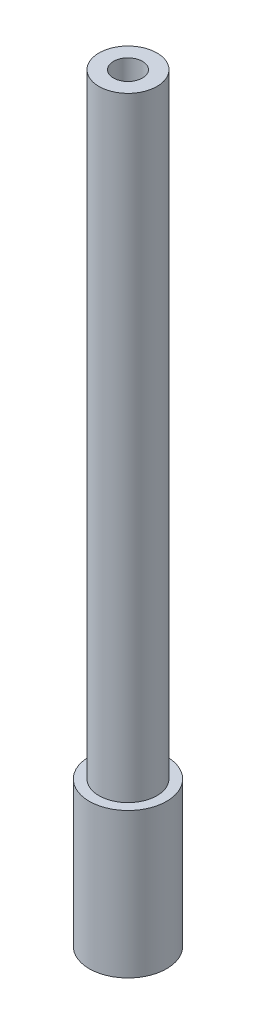
from build123d import *

# Parameters (mm, degrees)
SKETCH1_R           = 4
BOSS_EXTRUDE1_DEPTH = 15
SKETCH2_R           = 3
BOSS_EXTRUDE2_DEPTH = 59.52
SKETCH3_R           = 2.425
SKETCH3_R_2         = 1.02
CUT_EXTRUDE1_DEPTH  = 4
SKETCH4_R           = 3
BOSS_EXTRUDE3_DEPTH = 4
SKETCH5_R           = 1.5
CUT_EXTRUDE2_DEPTH  = 50


with BuildPart() as part:
    # Sketch1 → Boss-Extrude1 (new body)
    with BuildSketch(Plane(origin=(0, 0, 0), x_dir=(1, 0, 0), z_dir=(0, 1, 0))):
        Circle(SKETCH1_R)
    extrude(amount=BOSS_EXTRUDE1_DEPTH)

    # Sketch2 → Boss-Extrude2 (add)
    with BuildSketch(Plane(origin=(0, 15, 0), x_dir=(1, 0, 0), z_dir=(0, 1, 0))):
        Circle(SKETCH2_R)
    extrude(amount=BOSS_EXTRUDE2_DEPTH)

    # Sketch3 → Cut-Extrude1 (cut)
    with BuildSketch(Plane.XZ):
        Circle(SKETCH3_R)
        Circle(SKETCH3_R_2, mode=Mode.SUBTRACT)
    extrude(amount=-CUT_EXTRUDE1_DEPTH, mode=Mode.SUBTRACT)

    # Sketch4 → Boss-Extrude3 (add)
    with BuildSketch(Plane(origin=(0, 74.52, 0), x_dir=(1, 0, 0), z_dir=(0, 1, 0))):
        Circle(SKETCH4_R)
    extrude(amount=BOSS_EXTRUDE3_DEPTH)

    # Sketch5 → Cut-Extrude2 (cut)
    with BuildSketch(Plane(origin=(0, 78.52, 0), x_dir=(1, 0, 0), z_dir=(0, 1, 0))):
        Circle(SKETCH5_R)
    extrude(amount=-CUT_EXTRUDE2_DEPTH, mode=Mode.SUBTRACT)


solid = part.part
